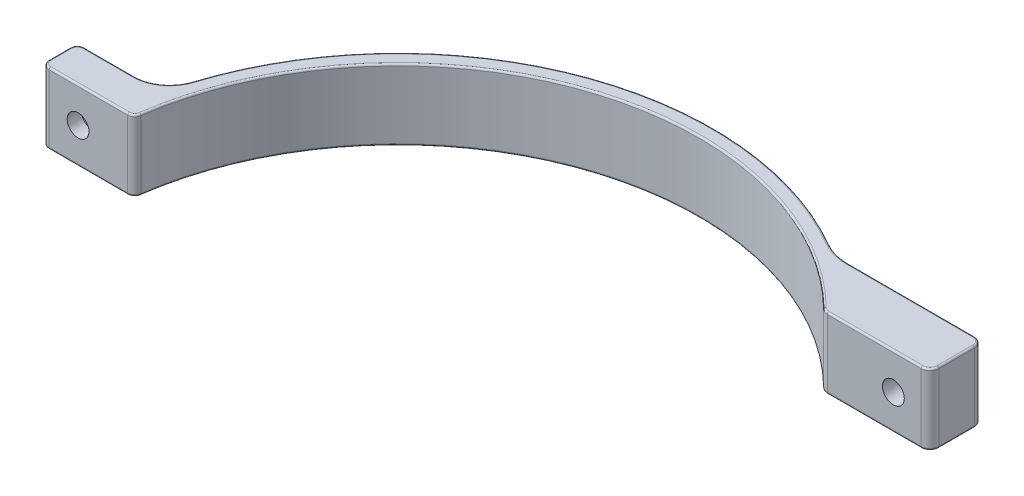
from build123d import *

# Parameters (mm, degrees)
RESSALTO_EXTRUS_O1_DEPTH   = 20
ESBO_O3_R                  = 3.075
CORTE_EXTRUS_O1_DEPTH      = 20
ESBO_O4_R                  = 5.25
CORTE_EXTRUS_O2_DEPTH      = 6
ESBO_O5_R                  = 3.075
CORTE_EXTRUS_O3_DEPTH      = 1
CORTE_EXTRUS_O3_DEPTH_BACK = 80
ESBO_O6_R                  = 5.25
CORTE_EXTRUS_O4_DEPTH      = 6
FILETE1_R                  = 0.5


with BuildPart() as part:
    # Esboço1 → Ressalto-extrusão1 (new body)
    with BuildSketch(Plane(origin=(0, 0, 0), x_dir=(1, 0, 0), z_dir=(0, 1, 0))):
        with BuildLine():
            Line((61.23724357, 60), (87.707972894, 60))
            ThreePointArc((87.707972894, 60), (89.475739847, 60.732233047), (90.207972894, 62.5))
            Line((90.207972894, 62.5), (90.207972894, 72.5))
            ThreePointArc((90.207972894, 72.5), (89.475739847, 74.267766953), (87.707972894, 75))
            Line((87.707972894, 75), (52.115256883, 75))
            ThreePointArc((52.115256883, 75), (48.223697971, 75.513600543), (44.598633294, 77.019230769))
            ThreePointArc((44.598633294, 77.019230769), (-32.102711223, 83.008529273), (-84.815301953, 26.96969697))
            ThreePointArc((-84.815301953, 26.96969697), (-88.441850634, 21.92835115), (-94.345111161, 20))
            Line((-94.345111161, 20), (-108.409715081, 20))
            ThreePointArc((-108.409715081, 20), (-109.823928643, 19.414213562), (-110.409715081, 18))
            Line((-110.409715081, 18), (-110.409715081, 12))
            ThreePointArc((-110.409715081, 12), (-109.823928643, 10.585786438), (-108.409715081, 10))
            Line((-108.409715081, 10), (-86.168439698, 10))
            ThreePointArc((-86.168439698, 10), (-84.855375369, 10.491403941), (-84.187556027, 11.724137931))
            ThreePointArc((-84.187556027, 11.724137931), (-27.432289416, 80.451659382), (59.487608039, 60.714285714))
            ThreePointArc((59.487608039, 60.714285714), (60.292332387, 60.185449751), (61.23724357, 60))
        make_face()
    extrude(amount=RESSALTO_EXTRUS_O1_DEPTH)

    # Esboço3 → Corte-extrusão1 (cut)
    with BuildSketch(Plane.XY.offset(-60)):
        with Locations((79.862425804, 9.799419725)):
            Circle(ESBO_O3_R)
    extrude(amount=-CORTE_EXTRUS_O1_DEPTH, mode=Mode.SUBTRACT)

    # Esboço4 → Corte-extrusão2 (cut)
    with BuildSketch(Plane(origin=(0, 0, -75), x_dir=(-1, 0, 0), z_dir=(0, 0, -1))):
        with Locations((-79.862425804, 9.799419725)):
            Circle(ESBO_O4_R)
    extrude(amount=-CORTE_EXTRUS_O2_DEPTH, mode=Mode.SUBTRACT)

    # Esboço5 → Corte-extrusão3 (cut, two sides)
    with BuildSketch(Plane.XY.offset(-10)) as corte_extrus_o3_sk:
        with Locations((-100.179715081, 10)):
            Circle(ESBO_O5_R)
    extrude(amount=CORTE_EXTRUS_O3_DEPTH, mode=Mode.SUBTRACT)
    extrude(corte_extrus_o3_sk.sketch, amount=-CORTE_EXTRUS_O3_DEPTH_BACK, mode=Mode.SUBTRACT)

    # Esboço6 → Corte-extrusão4 (cut)
    with BuildSketch(Plane(origin=(0, 0, -20), x_dir=(-1, 0, 0), z_dir=(0, 0, -1))):
        with Locations((100.179715081, 10)):
            Circle(ESBO_O6_R)
    extrude(amount=-CORTE_EXTRUS_O4_DEPTH, mode=Mode.SUBTRACT)

    # Filete1
    filete1_edges = [part.edges().sort_by_distance(p)[0] for p in [
        (-88.441850634, 20, -21.92835115),
        (69.911614889, 0, -75),
        (89.475739847, 0, -74.267766953),
        (90.207972894, 0, -67.5),
        (-101.377413121, 20, -20),
        (89.475739847, 0, -60.732233047),
        (74.472608232, 0, -60),
        (60.292332387, 0, -60.185449751),
        (-27.432289416, 0, -80.451659382),
        (-84.855375369, 0, -10.491403941),
        (-97.289077389, 0, -10),
        (-109.823928643, 0, -10.585786438),
        (-110.409715081, 0, -15),
        (-109.823928643, 0, -19.414213562),
        (-101.377413121, 0, -20),
        (-109.823928643, 20, -19.414213562),
        (-88.441850634, 0, -21.92835115),
        (-32.102711223, 0, -83.008529273),
        (48.223697971, 0, -75.513600543),
        (-110.409715081, 20, -15),
        (-109.823928643, 20, -10.585786438),
        (-97.289077389, 20, -10),
        (-84.855375369, 20, -10.491403941),
        (-27.432289416, 20, -80.451659382),
        (60.292332387, 20, -60.185449751),
        (74.472608232, 20, -60),
        (48.223697971, 20, -75.513600543),
        (89.475739847, 20, -60.732233047),
        (90.207972894, 20, -67.5),
        (89.475739847, 20, -74.267766953),
        (69.911614889, 20, -75),
        (-32.102711223, 20, -83.008529273),
    ]]
    fillet(filete1_edges, radius=FILETE1_R)


solid = part.part
